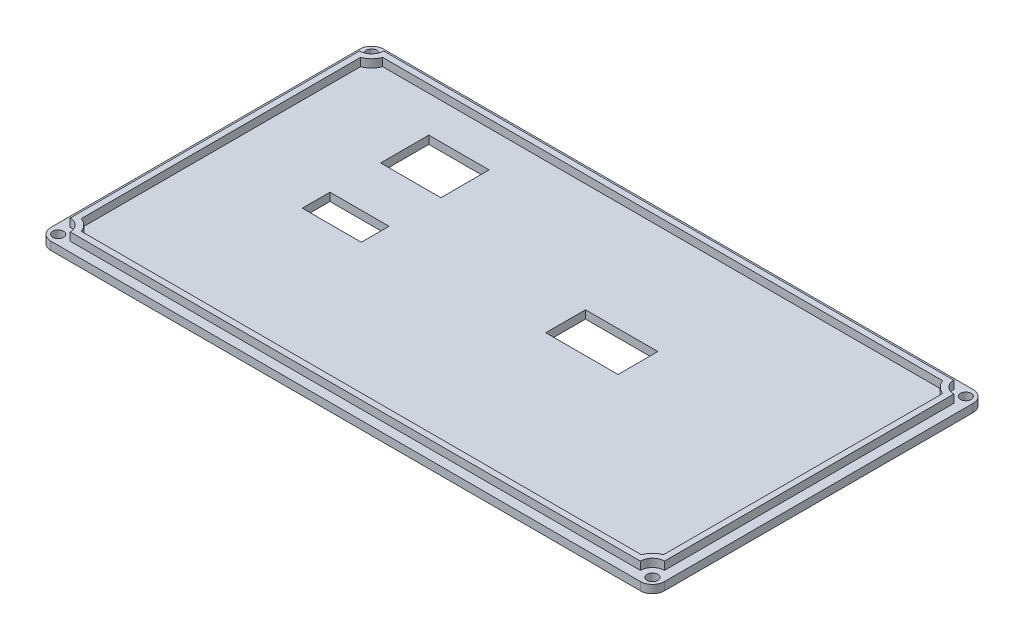
from build123d import *

# Parameters (mm, degrees)
SKETCH20_W            = 129.286
SKETCH20_H            = 70.104
BOSS_EXTRUDE5_DEPTH   = 1.699999902
BOSS_EXTRUDE6_DEPTH   = 1.7
FILLET3_R             = 2.54
F_4_40_TAPPED_HOLE3_D = 2.2606
SKETCH28_W            = 15.24
SKETCH28_H            = 8.382
SKETCH28_W_2          = 12.7
SKETCH28_H_2          = 10.16
SKETCH28_W_3          = 12.446
SKETCH28_H_3          = 5.842
CUT_EXTRUDE1_DEPTH    = 2.54


with BuildPart() as part:
    # Sketch20 → Boss-Extrude5 (new body)
    with BuildSketch(Plane(origin=(0, 0, 0), x_dir=(1, 0, 0), z_dir=(0, 1, 0))):
        with Locations((62.643, 54.832)):
            Rectangle(SKETCH20_W, SKETCH20_H)
    extrude(amount=-BOSS_EXTRUDE5_DEPTH)

    # Sketch20_3 → Boss-Extrude6 (add)
    with BuildSketch(Plane(origin=(0, 0, 0), x_dir=(1, 0, 0), z_dir=(0, 1, 0))):
        with BuildLine():
            Line((2.572, 21.812), (122.714, 21.812))
            ThreePointArc((122.714, 21.812), (123.457948776, 23.608051224), (125.254, 24.352))
            Line((125.254, 24.352), (125.254, 85.312))
            ThreePointArc((125.254, 85.312), (123.457948776, 86.055948776), (122.714, 87.852))
            Line((122.714, 87.852), (2.572, 87.852))
            ThreePointArc((2.572, 87.852), (1.828051224, 86.055948776), (0.032, 85.312))
            Line((0.032, 85.312), (0.032, 24.352))
            ThreePointArc((0.032, 24.352), (1.828051224, 23.608051224), (2.572, 21.812))
        make_face()
        with BuildLine():
            Line((3.624102448, 23.082), (121.661897552, 23.082))
            ThreePointArc((121.661897552, 23.082), (122.559923164, 24.506076836), (123.984, 25.404102448))
            Line((123.984, 25.404102448), (123.984, 84.259897552))
            ThreePointArc((123.984, 84.259897552), (122.559923164, 85.157923164), (121.661897552, 86.582))
            Line((121.661897552, 86.582), (3.624102448, 86.582))
            ThreePointArc((3.624102448, 86.582), (2.726076836, 85.157923164), (1.302, 84.259897552))
            Line((1.302, 84.259897552), (1.302, 25.404102448))
            ThreePointArc((1.302, 25.404102448), (2.726076836, 24.506076836), (3.624102448, 23.082))
        make_face(mode=Mode.SUBTRACT)
    extrude(amount=BOSS_EXTRUDE6_DEPTH)

    # Fillet3
    fillet3_edges = [part.edges().sort_by_distance(p)[0] for p in [
        (-2, -0.849999951, -19.78),
        (-2, -0.849999951, -89.884),
        (127.286, -0.849999951, -89.884),
        (127.286, -0.849999951, -19.78),
    ]]
    fillet(fillet3_edges, radius=FILLET3_R)

    # 4-40 Tapped Hole3 (through all)
    with Locations(Plane(origin=(0, 0, 0), x_dir=(1, 0, 0), z_dir=(0, 1, 0))):
        with Locations((0.032, 21.812), (125.254, 21.812), (125.254, 87.852), (0.032, 87.852)):
            Hole(F_4_40_TAPPED_HOLE3_D / 2)

    # Sketch28 → Cut-Extrude1 (cut)
    with BuildSketch(Plane.XZ.offset(1.699999902)):
        with Locations((76.994, -59.404)):
            Rectangle(SKETCH28_W, SKETCH28_H)
        with Locations((27.337, -73.882)):
            Rectangle(SKETCH28_W_2, SKETCH28_H_2)
        with Locations((27.21, -55.213)):
            Rectangle(SKETCH28_W_3, SKETCH28_H_3)
    extrude(amount=-CUT_EXTRUDE1_DEPTH, mode=Mode.SUBTRACT)


solid = part.part
